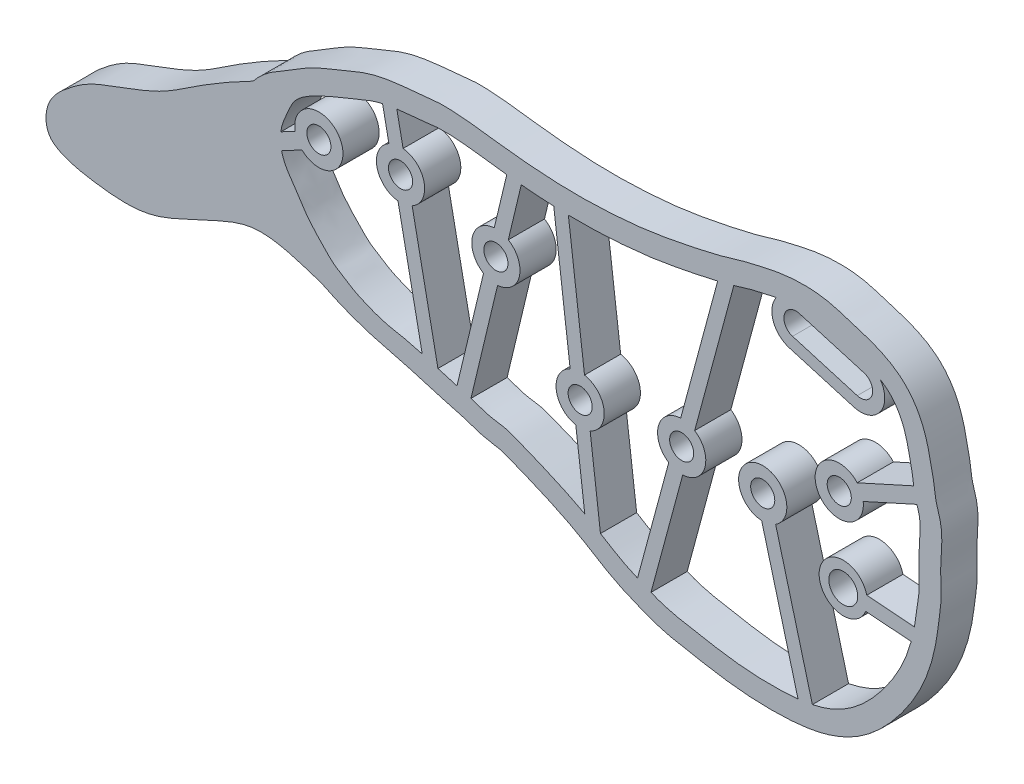
from build123d import *

# Parameters (mm, degrees)
SKETCH1_R           = 1
SKETCH1_R_2         = 1.2
BOSS_EXTRUDE2_DEPTH = 3


with BuildPart() as part:
    # Sketch1 → Boss-Extrude2 (new body)
    with BuildSketch(Plane.XY):
        with BuildLine():
            add(Edge.make_bspline(
                [(-55.557137207, -50.712757927), (-55.741468122, -50.622681276), (-56.481121268, -50.254917343), (-57.564594572, -49.674702168), (-58.758131843, -48.972784383), (-59.392971036, -48.570478494), (-59.700108672, -48.366583059)],
                knots=[0.968449644, 0.968449644, 0.968449644, 0.968449644, 0.972410887, 0.984375, 0.9921875, 1, 1, 1, 1], degree=3))
            add(Edge.make_bspline(
                [(-59.700108672, -48.366583059), (-60.007246307, -48.162687624), (-60.600957653, -47.749411774), (-61.439022618, -47.078020234), (-62.118369169, -46.306876644), (-62.576845524, -45.574937775), (-62.87520629, -44.655412207), (-62.947165004, -43.831789347), (-62.911056672, -43.096838915), (-62.767865816, -42.181420804), (-62.427926875, -41.103094902), (-61.929709055, -40.118623779), (-61.50444054, -39.445265962), (-61.271228495, -39.132555959), (-61.203521546, -39.046458879)],
                knots=[0, 0, 0, 0, 0.0078125, 0.015625, 0.01953125, 0.0234375, 0.02734375, 0.03125, 0.03515625, 0.0390625, 0.046875, 0.0546875, 0.059556158, 0.061422495, 0.061422495, 0.061422495, 0.061422495], degree=3))
            add(Edge.make_bspline(
                [(-61.203521546, -39.046458879), (-62.626622879, -39.787807984), (-65.210417208, -41.207290712), (-68.839105198, -43.837078), (-72.315997503, -44.996096121), (-74.989307349, -46.056957794), (-76.781078459, -47.382564153), (-78.474518554, -48.900218838), (-78.467785691, -51.470367805), (-76.487582336, -52.520400208), (-73.889871647, -52.986402531), (-69.80150655, -53.368035314), (-66.606242172, -51.626377408), (-63.716426715, -50.356582201), (-60.480283216, -48.926718306), (-57.323439675, -50.154355243), (-55.557137207, -50.712757927)],
                knots=[0, 0, 0, 0, 0.104944456, 0.193163139, 0.290920699, 0.343523479, 0.379953232, 0.436893195, 0.487497581, 0.515192694, 0.574607819, 0.662727431, 0.775391454, 0.804004211, 0.870669888, 1, 1, 1, 1], degree=3))
        make_face()
        with BuildLine():
            add(Edge.make_bspline(
                [(-59.700108672, -48.366583059), (-60.007246307, -48.162687624), (-60.600957653, -47.749411774), (-61.439022618, -47.078020234), (-62.118369169, -46.306876644), (-62.576845524, -45.574937775), (-62.87520629, -44.655412207), (-62.947165004, -43.831789347), (-62.911056672, -43.096838915), (-62.767865816, -42.181420804), (-62.427926875, -41.103094902), (-61.929709055, -40.118623779), (-61.50444054, -39.445265962), (-61.271228495, -39.132555959), (-61.203521546, -39.046458879)],
                knots=[0, 0, 0, 0, 0.0078125, 0.015625, 0.01953125, 0.0234375, 0.02734375, 0.03125, 0.03515625, 0.0390625, 0.046875, 0.0546875, 0.059556158, 0.061422495, 0.061422495, 0.061422495, 0.061422495], degree=3))
            add(Edge.make_bspline(
                [(-55.557137207, -50.712757927), (-55.741468122, -50.622681276), (-56.481121268, -50.254917343), (-57.564594572, -49.674702168), (-58.758131843, -48.972784383), (-59.392971036, -48.570478494), (-59.700108672, -48.366583059)],
                knots=[0.968449644, 0.968449644, 0.968449644, 0.968449644, 0.972410887, 0.984375, 0.9921875, 1, 1, 1, 1], degree=3))
            add(Edge.make_bspline(
                [(-61.203521546, -39.046458879), (-61.129517624, -38.952354481), (-60.790962988, -38.545150266), (-60.00992855, -37.833357535), (-59.003480445, -37.226613807), (-58.174355884, -36.753309633), (-57.327099252, -36.219280497), (-56.35540667, -35.641899148), (-55.216866917, -35.132998016), (-54.286405568, -34.792568791), (-53.431076372, -34.420336516), (-52.429050107, -33.988320977), (-51.255715995, -33.590566961), (-50.071749357, -33.365047886), (-49.045249247, -33.211118355), (-47.828145755, -33.12770735), (-47.12143284, -33.049002336), (-45.839380836, -32.880546371), (-44.653373281, -32.911203693), (-43.568648684, -32.995153988), (-42.157105186, -33.158201455), (-40.509490539, -33.384385954), (-38.545360024, -33.592996223), (-35.94093206, -33.785442844), (-33.340563194, -33.813434428), (-30.756650551, -33.658591183), (-28.794151513, -33.469344915), (-26.920072014, -33.176718817), (-24.950266667, -32.787264175), (-23.349670305, -32.441564839), (-22.265503841, -32.163576416), (-21.649462996, -31.989465622), (-21.209395475, -31.858003317), (-20.70946833, -31.694087893), (-19.878000454, -31.480073223), (-19.141228701, -31.321142419), (-18.028787086, -31.064804264), (-16.522498553, -30.8399239), (-14.928555409, -30.796819826), (-13.481718582, -31.019433242), (-12.630097062, -31.25552231), (-12.133022874, -31.420048336), (-11.641071775, -31.567860167), (-10.892105373, -31.79113893), (-9.867134365, -32.119976086), (-8.567891257, -32.681619373), (-7.251943186, -33.568215732), (-6.207946445, -34.848097455), (-5.559358006, -36.196531161), (-5.24082787, -37.288461776), (-5.059599258, -38.098819871), (-4.942470276, -38.683432648), (-4.858556094, -39.114969088), (-4.776359852, -39.498631382), (-4.6915535, -40.00454038), (-4.639432155, -40.488753846), (-4.581134865, -40.87740299), (-4.482267653, -41.2228333), (-4.281330913, -41.831954391), (-4.120278273, -42.584289582), (-4.074660997, -43.377507896), (-4.117108658, -44.293130411), (-4.178702696, -45.264132278), (-4.199333988, -45.90268337), (-4.160805911, -46.902477764), (-4.150607309, -47.86960419), (-4.224156466, -48.655438146), (-4.293047473, -49.07867096), (-4.340977262, -49.374251967), (-4.399984238, -49.843208023), (-4.482960411, -50.505770202), (-4.595762684, -51.187927583), (-4.778092827, -52.059583065), (-5.185128689, -53.528709325), (-6.014584451, -55.459122766), (-7.340063403, -57.5243487), (-8.997122359, -59.48461278), (-11.088016209, -61.213074577), (-13.707325444, -62.317349016), (-16.294682371, -62.685902223), (-18.682294173, -62.747561548), (-21.128740397, -62.598809444), (-23.078682593, -62.299942152), (-24.577811562, -62.030431001), (-25.688873174, -61.832858012), (-26.886827493, -61.590460849), (-27.955649277, -61.282855771), (-28.763818159, -60.966666791), (-29.289057886, -60.745807194), (-29.791224556, -60.541949914), (-30.356052376, -60.30784119), (-30.951834763, -60.030195804), (-31.695144696, -59.640385139), (-32.562422416, -59.130290554), (-33.529261963, -58.530765404), (-34.725263673, -57.822253588), (-36.296934147, -57.056747609), (-38.008786574, -56.293186993), (-39.304715566, -55.794524604), (-40.305882796, -55.370637628), (-40.653466322, -55.258144182), (-41.043684553, -55.190349433), (-41.681755677, -55.107184998), (-42.473969769, -54.909500536), (-43.070529415, -54.697293335), (-43.526200736, -54.540472453), (-43.997111467, -54.40549104), (-44.714816555, -54.216813434), (-45.667463991, -53.951074344), (-47.118242882, -53.521493631), (-48.849380765, -53.009205997), (-51.034512154, -52.507413324), (-53.222917439, -51.792290484), (-54.663492996, -51.143541615), (-55.377924281, -50.80033358), (-55.557137207, -50.712757927)],
                knots=[0.061422495, 0.061422495, 0.061422495, 0.061422495, 0.063462408, 0.0703125, 0.078125, 0.0859375, 0.09375, 0.1015625, 0.109375, 0.1171875, 0.125, 0.1328125, 0.140625, 0.1484375, 0.15625, 0.1640625, 0.171875, 0.1796875, 0.1875, 0.1953125, 0.203125, 0.21875, 0.234375, 0.25, 0.28125, 0.296875, 0.3125, 0.328125, 0.34375, 0.359375, 0.3671875, 0.37109375, 0.375, 0.37890625, 0.3828125, 0.390625, 0.3984375, 0.40625, 0.421875, 0.4296875, 0.43359375, 0.4375, 0.44140625, 0.4453125, 0.453125, 0.4609375, 0.46875, 0.4765625, 0.484375, 0.4921875, 0.49609375, 0.5, 0.50390625, 0.505859375, 0.5078125, 0.51171875, 0.515625, 0.51953125, 0.5234375, 0.52734375, 0.53125, 0.53515625, 0.5390625, 0.546875, 0.5546875, 0.5625, 0.56640625, 0.568359375, 0.5703125, 0.57421875, 0.578125, 0.58203125, 0.5859375, 0.59375, 0.609375, 0.625, 0.640625, 0.65625, 0.671875, 0.6875, 0.703125, 0.71875, 0.734375, 0.7421875, 0.75, 0.7578125, 0.765625, 0.76953125, 0.7734375, 0.77734375, 0.78125, 0.78515625, 0.7890625, 0.796875, 0.8046875, 0.8125, 0.828125, 0.84375, 0.8515625, 0.859375, 0.86328125, 0.8671875, 0.87109375, 0.875, 0.87890625, 0.8828125, 0.88671875, 0.890625, 0.8984375, 0.90625, 0.921875, 0.9375, 0.953125, 0.964598387, 0.968449644, 0.968449644, 0.968449644, 0.968449644], degree=3))
        make_face()
        with BuildLine():
            add(Edge.make_bspline(
                [(-45.877198196, -52.021605429), (-46.326725997, -51.886626051), (-46.768295448, -51.753166728), (-47.17927874, -51.634338102)],
                knots=[0.9028508, 0.9028508, 0.9028508, 0.9028508, 0.911921634, 0.911921634, 0.911921634, 0.911921634], degree=3))
            add(Edge.make_bspline(
                [(-47.17927874, -51.634338102), (-47.607785466, -51.510442881), (-49.051281147, -51.116057403), (-49.956591889, -51.137993561), (-52.624109319, -50.067378252), (-54.533334287, -48.773623589), (-54.363124516, -49.072138953), (-55.564813987, -47.808150693)],
                knots=[0.911921634, 0.911921634, 0.911921634, 0.911921634, 0.921379228, 0.946461202, 0.95944621, 0.96480009, 1, 1, 1, 1], degree=3))
            add(Edge.make_bspline(
                [(-55.564813987, -47.808150693), (-55.85220369, -47.50586194), (-56.934534646, -46.349810542), (-57.129220782, -45.752344642), (-58.456660169, -44.014118109), (-58.767375212, -43.196299317), (-58.845753024, -42.870352696)],
                knots=[0, 0, 0, 0, 0.008418225, 0.024991907, 0.034758713, 0.041561166, 0.041561166, 0.041561166, 0.041561166], degree=3))
            add(Edge.make_bspline(
                [(-58.845753024, -42.870352696), (-58.95707962, -42.407383302), (-58.969175533, -41.964197634), (-58.91155165, -41.544177251)],
                knots=[0.041561166, 0.041561166, 0.041561166, 0.041561166, 0.051223261, 0.051223261, 0.051223261, 0.051223261], degree=3))
            add(Edge.make_bspline(
                [(-58.91155165, -41.544177251), (-58.889986251, -41.3869871), (-58.762853102, -40.762300406), (-58.173622825, -39.486310111), (-57.732487765, -38.395215495), (-55.401868604, -37.151663648), (-53.241442652, -36.356967887), (-51.700962382, -35.604896269), (-50.637854914, -35.338202862), (-50.468661997, -35.300403531)],
                knots=[0.051223261, 0.051223261, 0.051223261, 0.051223261, 0.054839244, 0.065896336, 0.084165811, 0.104394653, 0.117879753, 0.139207419, 0.143214495, 0.143214495, 0.143214495, 0.143214495], degree=3))
            add(Edge.make_bspline(
                [(-50.468661997, -35.300403531), (-50.078437796, -35.213223679), (-49.682648099, -35.1493551), (-49.286182243, -35.093774884)],
                knots=[0.143214495, 0.143214495, 0.143214495, 0.143214495, 0.152456359, 0.152456359, 0.152456359, 0.152456359], degree=3))
            add(Edge.make_bspline(
                [(-49.286182243, -35.093774884), (-49.224872628, -35.08517994), (-48.967010694, -35.049873432), (-48.307136151, -34.965966355), (-47.299570479, -34.931229663), (-45.979263075, -34.696989184), (-43.965350969, -34.742046277), (-42.000053602, -35.027512709), (-40.552839224, -35.202161128), (-40.170139871, -35.245331847)],
                knots=[0.152456359, 0.152456359, 0.152456359, 0.152456359, 0.153885524, 0.158465695, 0.167836402, 0.177147849, 0.189373262, 0.214162697, 0.223063781, 0.223063781, 0.223063781, 0.223063781], degree=3))
            add(Edge.make_bspline(
                [(-40.170139871, -35.245331847), (-39.769201532, -35.29056003), (-39.367886526, -35.332526562), (-38.966216819, -35.370608455)],
                knots=[0.223063781, 0.223063781, 0.223063781, 0.223063781, 0.232389081, 0.232389081, 0.232389081, 0.232389081], degree=3))
            add(Edge.make_bspline(
                [(-38.966216819, -35.370608455), (-38.214772294, -35.441852139), (-37.317574416, -35.510568066), (-36.418817046, -35.554170508), (-36.274021288, -35.560535165)],
                knots=[0.232389081, 0.232389081, 0.232389081, 0.232389081, 0.249834871, 0.253184376, 0.253184376, 0.253184376, 0.253184376], degree=3))
            add(Edge.make_bspline(
                [(-36.274021288, -35.560535165), (-35.869619254, -35.578311103), (-35.464962683, -35.590951268), (-35.060222099, -35.59830608)],
                knots=[0.253184376, 0.253184376, 0.253184376, 0.253184376, 0.262539252, 0.262539252, 0.262539252, 0.262539252], degree=3))
            add(Edge.make_bspline(
                [(-35.060222099, -35.59830608), (-34.316751111, -35.611816188), (-33.377104055, -35.606353462), (-31.989235573, -35.553986576), (-30.88868161, -35.488679717), (-29.580808871, -35.371437263), (-27.643342783, -35.15780752), (-25.359873335, -34.730077136), (-23.484856168, -34.33660716), (-22.677861939, -34.141696104)],
                knots=[0.262539252, 0.262539252, 0.262539252, 0.262539252, 0.279723295, 0.284249287, 0.294647384, 0.305205595, 0.314605533, 0.339694174, 0.358901091, 0.358901091, 0.358901091, 0.358901091], degree=3))
            add(Edge.make_bspline(
                [(-22.677861939, -34.141696104), (-22.230044579, -34.033536032), (-21.784083643, -33.917893338), (-21.340729526, -33.791920752)],
                knots=[0.358901091, 0.358901091, 0.358901091, 0.358901091, 0.369559397, 0.369559397, 0.369559397, 0.369559397], degree=3))
            add(Edge.make_bspline(
                [(-21.340729526, -33.791920752), (-21.113370648, -33.727320053), (-20.681619661, -33.599099018), (-19.981167547, -33.371324186), (-19.07653807, -33.176676236), (-18.326720718, -32.992771616), (-17.861519172, -32.900111555), (-17.819333667, -32.891891629)],
                knots=[0.369559397, 0.369559397, 0.369559397, 0.369559397, 0.375025142, 0.379970152, 0.386561709, 0.39648446, 0.397474399, 0.397474399, 0.397474399, 0.397474399], degree=3))
            ThreePointArc((-17.819333667, -32.891891629), (-16.843099373, -32.158465909), (-15.622404683, -32.129291293))
            Line((-15.622404683, -32.129291293), (-10.258616171, -33.708423002))
            ThreePointArc((-10.258616171, -33.708423002), (-9.658482644, -34.001325127), (-9.188229866, -34.475470918))
            add(Edge.make_bspline(
                [(-9.188229866, -34.475470918), (-8.911386809, -34.647021387), (-8.155723837, -35.216564803), (-7.064960828, -36.942347809), (-6.787869597, -38.711398115), (-6.495376248, -40.093089606), (-6.45651198, -40.466160117), (-6.422944896, -40.725056729)],
                knots=[0.462896674, 0.462896674, 0.462896674, 0.462896674, 0.469592018, 0.482500714, 0.5040008, 0.5064167, 0.511856122, 0.511856122, 0.511856122, 0.511856122], degree=3))
            add(Edge.make_bspline(
                [(-6.422944896, -40.725056729), (-6.396538274, -40.928726042), (-6.336552463, -41.329643156), (-6.212626223, -41.729957687), (-6.153085375, -41.920157749)],
                knots=[0.511856122, 0.511856122, 0.511856122, 0.511856122, 0.516135218, 0.520264994, 0.520264994, 0.520264994, 0.520264994], degree=3))
            add(Edge.make_bspline(
                [(-6.153085375, -41.920157749), (-6.112147791, -42.050930681), (-5.938128897, -42.60237619), (-5.856693497, -43.21307599), (-5.954169854, -44.844023923), (-6.037801364, -46.299333731), (-5.87978281, -47.738839088), (-6.140874321, -49.206261935), (-6.226327922, -50.031726774), (-6.32773412, -50.647005839), (-6.360040002, -50.822991357)],
                knots=[0.520264994, 0.520264994, 0.520264994, 0.520264994, 0.52310444, 0.532522123, 0.536639379, 0.545132913, 0.566484196, 0.569736842, 0.578233294, 0.581710466, 0.581710466, 0.581710466, 0.581710466], degree=3))
            add(Edge.make_bspline(
                [(-6.360040002, -50.822991357), (-6.434969958, -51.231170491), (-6.525270742, -51.624861767), (-6.63059842, -52.006080548)],
                knots=[0.581710466, 0.581710466, 0.581710466, 0.581710466, 0.589775384, 0.589775384, 0.589775384, 0.589775384], degree=3))
            add(Edge.make_bspline(
                [(-6.63059842, -52.006080548), (-7.088854787, -53.664675299), (-8.627575964, -56.611789917), (-11.772771304, -59.766624996), (-14.163084678, -60.496665622), (-14.825927938, -60.634467333)],
                knots=[0.589775384, 0.589775384, 0.589775384, 0.589775384, 0.624863979, 0.662471395, 0.676446008, 0.676446008, 0.676446008, 0.676446008], degree=3))
            add(Edge.make_bspline(
                [(-14.825927938, -60.634467333), (-15.219487169, -60.716286277), (-15.618425716, -60.776959985), (-16.017972483, -60.821563745)],
                knots=[0.676446008, 0.676446008, 0.676446008, 0.676446008, 0.684743352, 0.684743352, 0.684743352, 0.684743352], degree=3))
            add(Edge.make_bspline(
                [(-16.017972483, -60.821563745), (-16.209485948, -60.842943521), (-16.761263614, -60.89386698), (-17.45738343, -60.925530561), (-18.450390865, -60.93967141), (-19.983011158, -60.912707913), (-22.16169672, -60.660995923), (-24.802454296, -60.178394861), (-26.827825026, -59.818466086), (-27.977238576, -59.360885443), (-28.20806687, -59.266041757)],
                knots=[0.684743352, 0.684743352, 0.684743352, 0.684743352, 0.688720491, 0.696193702, 0.699273238, 0.709375305, 0.728070074, 0.744780937, 0.765338705, 0.770526623, 0.770526623, 0.770526623, 0.770526623], degree=3))
            add(Edge.make_bspline(
                [(-28.20806687, -59.266041757), (-28.363772617, -59.202064735), (-28.735835994, -59.045962751), (-29.110096437, -58.895438491), (-29.326600137, -58.804932073)],
                knots=[0.770526623, 0.770526623, 0.770526623, 0.770526623, 0.774026144, 0.778908077, 0.778908077, 0.778908077, 0.778908077], degree=3))
            add(Edge.make_bspline(
                [(-29.326600137, -58.804932073), (-29.497869215, -58.73333537), (-30.568665773, -58.272114996), (-31.558829369, -57.648488218), (-32.39827863, -57.135752794)],
                knots=[0.778908077, 0.778908077, 0.778908077, 0.778908077, 0.782770016, 0.803185701, 0.803185701, 0.803185701, 0.803185701], degree=3))
            add(Edge.make_bspline(
                [(-32.39827863, -57.135752794), (-32.716359771, -56.941468903), (-33.14753817, -56.681178505), (-33.586838962, -56.436525528), (-33.701574206, -56.373877972)],
                knots=[0.803185701, 0.803185701, 0.803185701, 0.803185701, 0.810921541, 0.813640038, 0.813640038, 0.813640038, 0.813640038], degree=3))
            add(Edge.make_bspline(
                [(-33.701574206, -56.373877972), (-34.716520536, -55.819698581), (-36.136525646, -55.175548105), (-37.935718316, -54.402517893), (-39.058089661, -53.978781057), (-40.219182584, -53.458207666), (-41.564574543, -53.376566237), (-42.523379293, -52.990371743), (-43.052564378, -52.826456807), (-43.139597884, -52.800477482)],
                knots=[0.813640038, 0.813640038, 0.813640038, 0.813640038, 0.837687832, 0.846032736, 0.854360406, 0.862697319, 0.872259041, 0.882003653, 0.883915676, 0.883915676, 0.883915676, 0.883915676], degree=3))
            add(Edge.make_bspline(
                [(-43.139597884, -52.800477482), (-43.488084129, -52.696455042), (-43.869161475, -52.599646202), (-44.267066249, -52.490509785), (-44.297303004, -52.482174532)],
                knots=[0.883915676, 0.883915676, 0.883915676, 0.883915676, 0.891571508, 0.892199111, 0.892199111, 0.892199111, 0.892199111], degree=3))
            add(Edge.make_bspline(
                [(-44.297303004, -52.482174532), (-44.810482032, -52.340708387), (-45.349327123, -52.180108883), (-45.877198196, -52.021605429)],
                knots=[0.892199111, 0.892199111, 0.892199111, 0.892199111, 0.9028508, 0.9028508, 0.9028508, 0.9028508], degree=3))
        make_face(mode=Mode.SUBTRACT)
        with BuildLine():
            Line((-10.611540517, -43.93911042), (-6.153085375, -41.920157749))
            add(Edge.make_bspline(
                [(-6.422944896, -40.725056729), (-6.396538274, -40.928726042), (-6.336552463, -41.329643156), (-6.212626223, -41.729957687), (-6.153085375, -41.920157749)],
                knots=[0.511856122, 0.511856122, 0.511856122, 0.511856122, 0.516135218, 0.520264994, 0.520264994, 0.520264994, 0.520264994], degree=3))
            Line((-6.422944896, -40.725056729), (-11.1065556, -42.84596813))
            ThreePointArc((-11.1065556, -42.84596813), (-14.418937348, -45.004588238), (-10.611540517, -43.93911042))
        make_face()
        with Locations((-12.597033531, -44.179563098)):
            Circle(SKETCH1_R, mode=Mode.SUBTRACT)
        with BuildLine():
            ThreePointArc((-15.622404683, -32.129291293), (-16.843099373, -32.158465909), (-17.819333667, -32.891891629))
            add(Edge.make_bspline(
                [(-17.819333667, -32.891891629), (-17.215010581, -32.774138136), (-15.762178648, -32.581677787), (-14.01309573, -32.711321001), (-11.85580662, -33.432170961), (-10.236885738, -33.825653621), (-9.188229866, -34.475470918)],
                knots=[0.397474399, 0.397474399, 0.397474399, 0.397474399, 0.411655644, 0.431741695, 0.437535332, 0.462896674, 0.462896674, 0.462896674, 0.462896674], degree=3))
            ThreePointArc((-9.188229866, -34.475470918), (-9.658482644, -34.001325127), (-10.258616171, -33.708423002))
            Line((-10.258616171, -33.708423002), (-15.622404683, -32.129291293))
        make_face()
        with BuildLine():
            add(Edge.make_bspline(
                [(-17.819333667, -32.891891629), (-17.215010581, -32.774138136), (-15.762178648, -32.581677787), (-14.01309573, -32.711321001), (-11.85580662, -33.432170961), (-10.236885738, -33.825653621), (-9.188229866, -34.475470918)],
                knots=[0.397474399, 0.397474399, 0.397474399, 0.397474399, 0.411655644, 0.431741695, 0.437535332, 0.462896674, 0.462896674, 0.462896674, 0.462896674], degree=3))
            ThreePointArc((-17.819333667, -32.891891629), (-18.076653097, -34.703725269), (-16.752088427, -35.966453609))
            Line((-16.752088427, -35.966453609), (-11.388299915, -37.545585318))
            ThreePointArc((-11.388299915, -37.545585318), (-9.19777901, -36.791979559), (-9.188229866, -34.475470918))
        make_face()
        with BuildLine():
            ThreePointArc((-16.469667491, -35.00716303), (-17.146537134, -33.765451515), (-15.904825619, -33.088581872))
            Line((-15.904825619, -33.088581872), (-10.541037107, -34.667713581))
            ThreePointArc((-10.541037107, -34.667713581), (-9.864167464, -35.909425096), (-11.105878979, -36.586294739))
            Line((-11.105878979, -36.586294739), (-16.469667491, -35.00716303))
        make_face(mode=Mode.SUBTRACT)
        with BuildLine():
            Line((-10.407332689, -51.723051114), (-6.63059842, -52.006080548))
            add(Edge.make_bspline(
                [(-6.360040002, -50.822991357), (-6.434969958, -51.231170491), (-6.525270742, -51.624861767), (-6.63059842, -52.006080548)],
                knots=[0.581710466, 0.581710466, 0.581710466, 0.581710466, 0.589775384, 0.589775384, 0.589775384, 0.589775384], degree=3))
            Line((-6.360040002, -50.822991357), (-10.317655843, -50.526406612))
            ThreePointArc((-10.317655843, -50.526406612), (-14.25944527, -50.832690356), (-10.407332689, -51.723051114))
        make_face()
        with Locations((-12.265037767, -50.982151765)):
            Circle(SKETCH1_R_2, mode=Mode.SUBTRACT)
        with BuildLine():
            Line((-19.031686126, -49.521159662), (-16.017972483, -60.821563745))
            add(Edge.make_bspline(
                [(-14.825927938, -60.634467333), (-15.219487169, -60.716286277), (-15.618425716, -60.776959985), (-16.017972483, -60.821563745)],
                knots=[0.676446008, 0.676446008, 0.676446008, 0.676446008, 0.684743352, 0.684743352, 0.684743352, 0.684743352], degree=3))
            Line((-14.825927938, -60.634467333), (-17.872211162, -49.211938373))
            ThreePointArc((-17.872211162, -49.211938373), (-19.458947976, -45.590643039), (-19.031686126, -49.521159662))
        make_face()
        with Locations((-18.94357916, -47.523101314)):
            Circle(SKETCH1_R, mode=Mode.SUBTRACT)
        with BuildLine():
            Line((-26.739731533, -49.209043516), (-29.326600137, -58.804932073))
            add(Edge.make_bspline(
                [(-28.20806687, -59.266041757), (-28.363772617, -59.202064735), (-28.735835994, -59.045962751), (-29.110096437, -58.895438491), (-29.326600137, -58.804932073)],
                knots=[0.770526623, 0.770526623, 0.770526623, 0.770526623, 0.774026144, 0.778908077, 0.778908077, 0.778908077, 0.778908077], degree=3))
            Line((-28.20806687, -59.266041757), (-25.581094533, -49.521389961))
            ThreePointArc((-25.581094533, -49.521389961), (-23.732752169, -48.043678723), (-24.587896138, -45.837159112))
            Line((-24.587896138, -45.837159112), (-21.340729526, -33.791920752))
            add(Edge.make_bspline(
                [(-22.677861939, -34.141696104), (-22.230044579, -34.033536032), (-21.784083643, -33.917893338), (-21.340729526, -33.791920752)],
                knots=[0.358901091, 0.358901091, 0.358901091, 0.358901091, 0.369559397, 0.369559397, 0.369559397, 0.369559397], degree=3))
            Line((-22.677861939, -34.141696104), (-25.746533138, -45.524812667))
            ThreePointArc((-25.746533138, -45.524812667), (-27.594875503, -47.002523906), (-26.739731533, -49.209043516))
        make_face()
        with Locations((-25.663813836, -47.523101314)):
            Circle(SKETCH1_R, mode=Mode.SUBTRACT)
        with BuildLine():
            Line((-34.445717171, -50.353111693), (-33.701574206, -56.373877972))
            add(Edge.make_bspline(
                [(-32.39827863, -57.135752794), (-32.716359771, -56.941468903), (-33.14753817, -56.681178505), (-33.586838962, -56.436525528), (-33.701574206, -56.373877972)],
                knots=[0.803185701, 0.803185701, 0.803185701, 0.803185701, 0.810921541, 0.813640038, 0.813640038, 0.813640038, 0.813640038], degree=3))
            Line((-32.39827863, -57.135752794), (-33.254779072, -50.205916441))
            ThreePointArc((-33.254779072, -50.205916441), (-32.099376824, -48.140717747), (-33.722830142, -46.418974641))
            Line((-33.722830142, -46.418974641), (-35.060222099, -35.59830608))
            add(Edge.make_bspline(
                [(-36.274021288, -35.560535165), (-35.869619254, -35.578311103), (-35.464962683, -35.590951268), (-35.060222099, -35.59830608)],
                knots=[0.253184376, 0.253184376, 0.253184376, 0.253184376, 0.262539252, 0.262539252, 0.262539252, 0.262539252], degree=3))
            Line((-36.274021288, -35.560535165), (-34.913768242, -46.566169893))
            ThreePointArc((-34.913768242, -46.566169893), (-36.06917049, -48.631368587), (-34.445717171, -50.353111693))
        make_face()
        with Locations((-34.084273657, -48.386043167)):
            Circle(SKETCH1_R, mode=Mode.SUBTRACT)
        with BuildLine():
            add(Edge.make_bspline(
                [(-58.845753024, -42.870352696), (-58.95707962, -42.407383302), (-58.969175533, -41.964197634), (-58.91155165, -41.544177251)],
                knots=[0.041561166, 0.041561166, 0.041561166, 0.041561166, 0.051223261, 0.051223261, 0.051223261, 0.051223261], degree=3))
            Line((-58.845753024, -42.870352696), (-57.151241544, -41.962315387))
            ThreePointArc((-57.151241544, -41.962315387), (-53.990144516, -39.587661898), (-57.718034937, -40.904607843))
            Line((-57.718034937, -40.904607843), (-58.91155165, -41.544177251))
        make_face()
        with Locations((-55.752990423, -40.532317553)):
            Circle(SKETCH1_R, mode=Mode.SUBTRACT)
        with BuildLine():
            Line((-42.098251113, -43.297969722), (-44.297303004, -52.482174532))
            add(Edge.make_bspline(
                [(-43.139597884, -52.800477482), (-43.488084129, -52.696455042), (-43.869161475, -52.599646202), (-44.267066249, -52.490509785), (-44.297303004, -52.482174532)],
                knots=[0.883915676, 0.883915676, 0.883915676, 0.883915676, 0.891571508, 0.892199111, 0.892199111, 0.892199111, 0.892199111], degree=3))
            Line((-43.139597884, -52.800477482), (-40.931237804, -43.577397596))
            ThreePointArc((-40.931237804, -43.577397596), (-39.125460272, -42.047963876), (-40.042713794, -39.866531783))
            Line((-40.042713794, -39.866531783), (-38.966216819, -35.370608455))
            add(Edge.make_bspline(
                [(-40.170139871, -35.245331847), (-39.769201532, -35.29056003), (-39.367886526, -35.332526562), (-38.966216819, -35.370608455)],
                knots=[0.223063781, 0.223063781, 0.223063781, 0.223063781, 0.232389081, 0.232389081, 0.232389081, 0.232389081], degree=3))
            Line((-40.170139871, -35.245331847), (-41.209727103, -39.587103909))
            ThreePointArc((-41.209727103, -39.587103909), (-43.015504635, -41.116537629), (-42.098251113, -43.297969722))
        make_face()
        with Locations((-41.070482454, -41.582250752)):
            Circle(SKETCH1_R, mode=Mode.SUBTRACT)
        with BuildLine():
            Line((-49.190925199, -41.645200604), (-47.17927874, -51.634338102))
            add(Edge.make_bspline(
                [(-45.877198196, -52.021605429), (-46.326725997, -51.886626051), (-46.768295448, -51.753166728), (-47.17927874, -51.634338102)],
                knots=[0.9028508, 0.9028508, 0.9028508, 0.9028508, 0.911921634, 0.911921634, 0.911921634, 0.911921634], degree=3))
            Line((-45.877198196, -52.021605429), (-48.014542391, -41.408296636))
            ThreePointArc((-48.014542391, -41.408296636), (-47.018749086, -39.261579213), (-48.767848998, -37.667637716))
            Line((-48.767848998, -37.667637716), (-49.286182243, -35.093774884))
            add(Edge.make_bspline(
                [(-50.468661997, -35.300403531), (-50.078437796, -35.213223679), (-49.682648099, -35.1493551), (-49.286182243, -35.093774884)],
                knots=[0.143214495, 0.143214495, 0.143214495, 0.143214495, 0.152456359, 0.152456359, 0.152456359, 0.152456359], degree=3))
            Line((-50.468661997, -35.300403531), (-49.944231805, -37.904541684))
            ThreePointArc((-49.944231805, -37.904541684), (-50.940025111, -40.051259106), (-49.190925199, -41.645200604))
        make_face()
        with Locations((-48.979387098, -39.65641916)):
            Circle(SKETCH1_R, mode=Mode.SUBTRACT)
    extrude(amount=BOSS_EXTRUDE2_DEPTH)


solid = part.part
